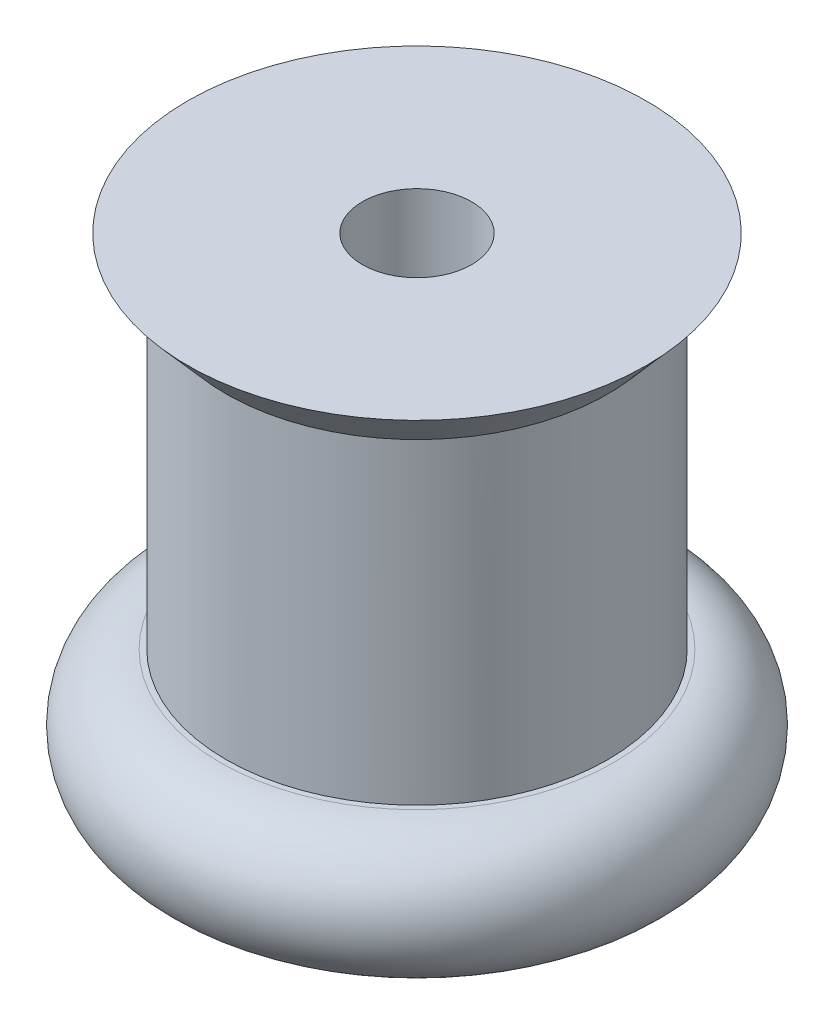
from build123d import *

# Parameters (mm, degrees)
SKETCH1_R           = 12
SKETCH1_R_2         = 2.5
BOSS_EXTRUDE1_DEPTH = 6
SKETCH2_R           = 8.750000000000002
SKETCH2_R_2         = 2.5
BOSS_EXTRUDE2_DEPTH = 14.5
SKETCH3_R           = 10.5
SKETCH3_R_2         = 2.5
BOSS_EXTRUDE3_DEPTH = 2


with BuildPart() as part:
    # Sketch1 → Boss-Extrude1 (new body)
    with BuildSketch(Plane(origin=(0, 0, 0), x_dir=(1, 0, 0), z_dir=(0, 1, 0))):
        with Locations(Location((0, 0, 0), (0, 0, 270))):
            Circle(SKETCH1_R)
        with Locations(Location((0, 0, 0), (0, 0, 270))):
            Circle(SKETCH1_R_2, mode=Mode.SUBTRACT)
    extrude(amount=BOSS_EXTRUDE1_DEPTH)

    # Sketch2 → Boss-Extrude2 (add)
    with BuildSketch(Plane(origin=(0, 6, 0), x_dir=(1, 0, 0), z_dir=(0, 1, 0))):
        with Locations(Location((0, 0, 0), (0, 0, 90))):
            Circle(SKETCH2_R)
        with Locations(Location((0, 0, 0), (0, 0, 270))):
            Circle(SKETCH2_R_2, mode=Mode.SUBTRACT)
    extrude(amount=BOSS_EXTRUDE2_DEPTH)

    # Sketch3 → Boss-Extrude3 (add)
    with BuildSketch(Plane(origin=(0, 20.5, 0), x_dir=(1, 0, 0), z_dir=(0, 1, 0))):
        with Locations(Location((0, 0, 0), (0, 0, 270))):
            Circle(SKETCH3_R)
        with Locations(Location((0, 0, 0), (0, 0, 270))):
            Circle(SKETCH3_R_2, mode=Mode.SUBTRACT)
    extrude(amount=BOSS_EXTRUDE3_DEPTH)

    # Cut-Sweep3: sweep along a curve in space
    with BuildLine() as cut_sweep3_path:
        ThreePointArc((0, 20.5, 8.750000000000002), (6.187184335382292, 20.5, 6.187184335382293), (8.750000000000002, 20.5, 0))
        ThreePointArc((8.750000000000002, 20.5, 0), (6.187184335382293, 20.5, -6.187184335382292), (0, 20.5, -8.750000000000002))
        ThreePointArc((0, 20.5, -8.750000000000002), (-6.187184335382292, 20.5, -6.187184335382293), (-8.750000000000002, 20.5, 0))
        ThreePointArc((-8.750000000000002, 20.5, 0), (-6.187184335382293, 20.5, 6.187184335382292), (0, 20.5, 8.750000000000002))
    # Sketch5 → Cut-Sweep3 (sweep, cut)
    with BuildSketch(Plane.XY):
        Polygon((-10.5, 22.5), (-8.750000000000002, 20.5), (-10.5, 20.5), align=None)
    sweep(path=cut_sweep3_path.line, mode=Mode.SUBTRACT)

    # Cut-Sweep4: sweep along a curve in space
    with BuildLine() as cut_sweep4_path:
        ThreePointArc((0, 6, 12.000000000000002), (8.485281374238571, 6, 8.485281374238571), (12.000000000000002, 6, 0))
        ThreePointArc((12.000000000000002, 6, 0), (8.485281374238571, 6, -8.485281374238571), (0, 6, -12.000000000000002))
        ThreePointArc((0, 6, -12.000000000000002), (-8.485281374238571, 6, -8.485281374238571), (-12.000000000000002, 6, 0))
        ThreePointArc((-12.000000000000002, 6, 0), (-8.485281374238571, 6, 8.485281374238571), (0, 6, 12.000000000000002))
    # Sketch6 → Cut-Sweep4 (sweep, cut)
    with BuildSketch(Plane.XY):
        with BuildLine():
            Line((-12.000000000000002, 3), (-12.000000000000002, 6))
            Line((-12.000000000000002, 6), (-9.000000000000002, 6.000000000000002))
            ThreePointArc((-9.000000000000002, 6.000000000000002), (-11.121320343559645, 5.121320343559644), (-12.000000000000002, 3))
        make_face()
    sweep(path=cut_sweep4_path.line, mode=Mode.SUBTRACT)

    # Cut-Sweep5: sweep along a curve in space
    with BuildLine() as cut_sweep5_path:
        ThreePointArc((0, 0, 12.000000000000002), (8.485281374238571, 0, 8.485281374238571), (12.000000000000002, 0, 0))
        ThreePointArc((12.000000000000002, 0, 0), (8.485281374238571, 0, -8.485281374238571), (0, 0, -12.000000000000002))
        ThreePointArc((0, 0, -12.000000000000002), (-8.485281374238571, 0, -8.485281374238571), (-12.000000000000002, 0, 0))
        ThreePointArc((-12.000000000000002, 0, 0), (-8.485281374238571, 0, 8.485281374238571), (0, 0, 12.000000000000002))
    # Sketch7 → Cut-Sweep5 (sweep, cut)
    with BuildSketch(Plane.XY):
        with BuildLine():
            Line((-9.000000000000002, -1.3e-15), (-12.000000000000002, 0))
            Line((-12.000000000000002, 0), (-12.000000000000002, 2.999999999999979))
            ThreePointArc((-12.000000000000002, 2.999999999999979), (-11.121320343559637, 0.8786796564403496), (-9.000000000000002, -1.3e-15))
        make_face()
    sweep(path=cut_sweep5_path.line, mode=Mode.SUBTRACT)


solid = part.part
